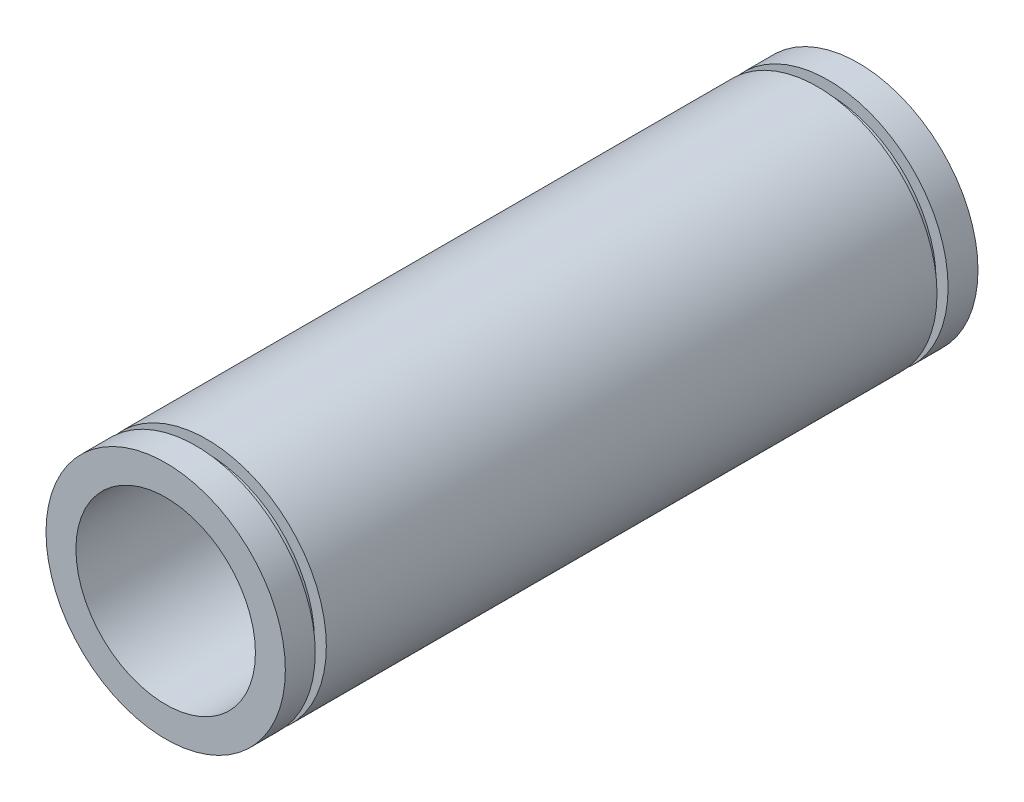
from build123d import *

# Parameters (mm, degrees)
SKETCH1_R               = 20
BOSS_EXTRUDE1_DEPTH     = 52.8796
SKETCH2_R               = 20
SKETCH2_R_2             = 18
CUT_EXTRUDE2_DEPTH      = 1.85
SKETCH6_R               = 20
BOSS_EXTRUDE2_DEPTH     = 5
SKETCH7_R               = 15
CUT_EXTRUDE3_DEPTH      = 1
CUT_EXTRUDE3_DEPTH_BACK = 116.7592


with BuildPart() as part:
    # Sketch1 → Boss-Extrude1 (new body)
    with BuildSketch(Plane.XY):
        Circle(SKETCH1_R)
    extrude(amount=BOSS_EXTRUDE1_DEPTH)

    # Sketch2 → Cut-Extrude2 (cut)
    with BuildSketch(Plane.XY.offset(52.8796)):
        Circle(SKETCH2_R)
        Circle(SKETCH2_R_2, mode=Mode.SUBTRACT)
    extrude(amount=-CUT_EXTRUDE2_DEPTH, mode=Mode.SUBTRACT)

    # Sketch6 → Boss-Extrude2 (add)
    with BuildSketch(Plane.XY.offset(52.8796)):
        Circle(SKETCH6_R)
    extrude(amount=BOSS_EXTRUDE2_DEPTH)

    # Mirror2: part across plane


with BuildPart() as part_1:
    add(part.part)
    add(part.part.mirror(Plane.XY))

    # Sketch7 → Cut-Extrude3 (cut, two sides)
    with BuildSketch(Plane(origin=(0, 0, -57.8796), x_dir=(-1, 0, 0), z_dir=(0, 0, -1))) as cut_extrude3_sk:
        Circle(SKETCH7_R)
    extrude(amount=CUT_EXTRUDE3_DEPTH, mode=Mode.SUBTRACT)
    extrude(cut_extrude3_sk.sketch, amount=-CUT_EXTRUDE3_DEPTH_BACK, mode=Mode.SUBTRACT)


solid = part_1.part
